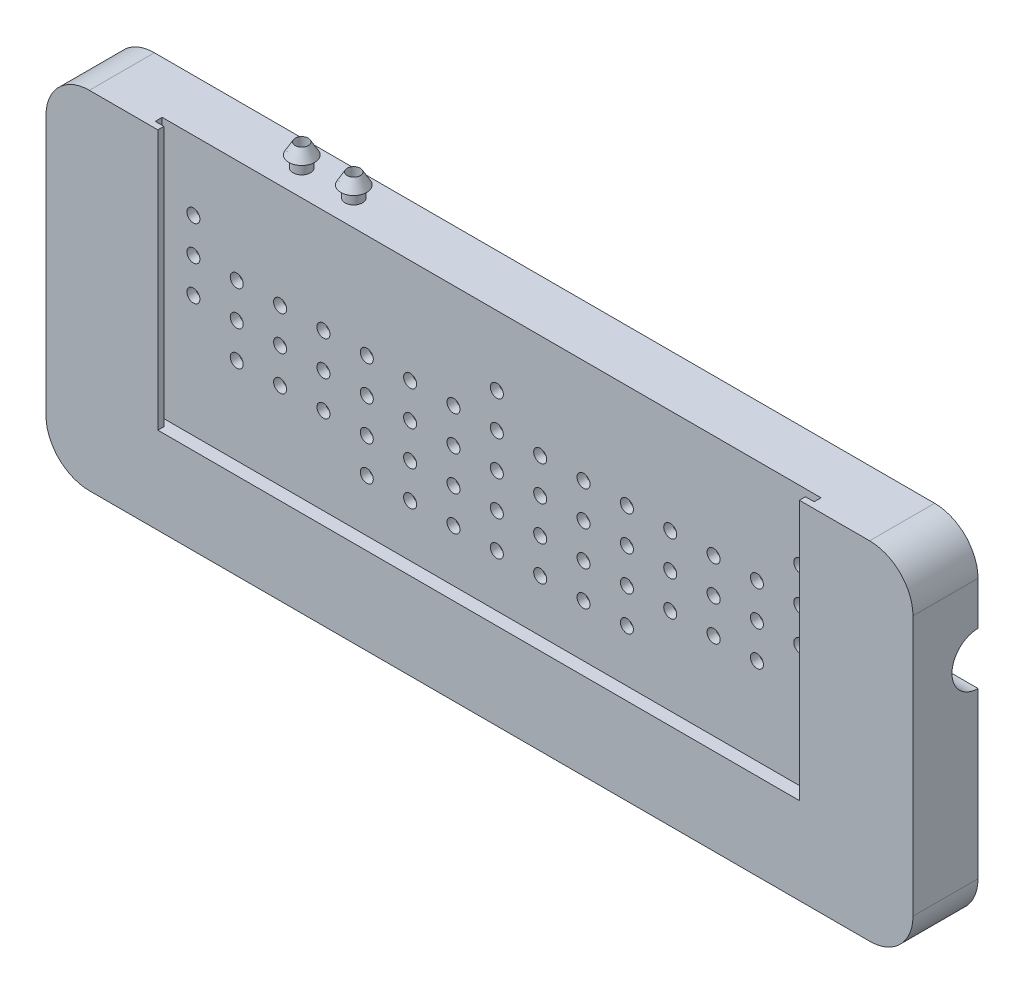
from build123d import *

# Parameters (mm, degrees)
CROQUIS2_W               = 50
CROQUIS2_H               = 40
SALIENTE_EXTRUIR1_DEPTH  = 7.5
CORTAR_EXTRUIR1_DEPTH    = 5
REDONDEO1_R              = 5
CROQUIS5_W               = 12.5
CROQUIS5_H               = 7.5
CORTAR_EXTRUIR2_DEPTH    = 3.5
CROQUIS6_W               = 12.5
CROQUIS6_H               = 3.5
SALIENTE_EXTRUIR5_DEPTH  = 3.5
CORTAR_EXTRUIR3_DEPTH    = 10
CROQUIS4_R               = 4
CORTAR_EXTRUIR4_DEPTH    = 3
CROQUIS9_W               = 102
CROQUIS9_H               = 42
CORTAR_EXTRUIR5_DEPTH    = 13
CROQUIS10_W              = 12.5
CROQUIS10_H              = 4
SALIENTE_EXTRUIR6_DEPTH  = 3.5
CROQUIS12_R              = 0.75
CROQUIS12_R_2            = 0.750000002
CORTAR_EXTRUIR6_DEPTH    = 2.5
CORTAR_EXTRUIR7_DEPTH    = 30
CORTAR_EXTRUIR8_REACH    = 87.33
CROQUIS17_R              = 0.75
CROQUIS18_R              = 1
CROQUIS18_R_2            = 0.75
SALIENTE_EXTRUIR9_DEPTH  = 1.3
CROQUIS20_R              = 1
CROQUIS20_R_2            = 0.75
SALIENTE_EXTRUIR10_DEPTH = 1.3
MATRIZL1_COUNT           = 2
MATRIZL1_PITCH           = 6
CORTAR_EXTRUIR10_REACH   = 88.579
CROQUIS22_R              = 0.75
CROQUIS23_R              = 1
CROQUIS23_R_2            = 0.75
SALIENTE_EXTRUIR11_DEPTH = 1.3
MATRIZL2_COUNT           = 2
MATRIZL2_PITCH           = 6
MATRIZL3_COUNT           = 2
MATRIZL3_PITCH           = 6


with BuildPart() as part:
    # Croquis2 → Saliente-Extruir1 (new body)
    with BuildSketch(Plane.XY):
        Rectangle(CROQUIS2_W, CROQUIS2_H)
    saliente_extruir1 = extrude(amount=SALIENTE_EXTRUIR1_DEPTH)

    # Croquis3 → Cortar-Extruir1 (cut)
    with BuildSketch(Plane.XY.offset(7.5)):
        with BuildLine():
            Line((19.901237938, 10.279897032), (22.822017531, 17.279897032))
            Line((22.822017531, 17.279897032), (24, 15.279897032))
            Line((24, 15.279897032), (25, 15.279897032))
            Line((25, 15.279897032), (25, -14.629122871))
            ThreePointArc((25, -14.629122871), (20.554365751, -11.20741121), (15.817639155, -8.201550981))
            add(Edge.make_bspline(
                [(15.817639155, -8.201550981), (6.428363836, -3.289480245), (3.480591711, -7.371484759)],
                knots=[5.017938201, 5.017938201, 5.017938201, 6.283185307, 6.283185307, 6.283185307], degree=2, weights=[1, 0.806479077, 1]))
            add(Edge.make_bspline(
                [(3.480591711, -7.371484759), (3.499026777, -1.865901054), (-8.816349071, -0.309137944)],
                knots=[3.141592654, 3.141592654, 3.141592654, 4.433520913, 4.433520913, 4.433520913], degree=2, weights=[1, 0.798519762, 1]))
            ThreePointArc((-8.816349071, -0.309137944), (-13.59205679, -0.015988385), (-18.376149655, -0.091990716))
            ThreePointArc((-18.376149655, -0.091990716), (-14.787337114, 10.909903735), (-5.334178799, 17.585160647))
            add(Edge.make_bspline(
                [(-5.334178799, 17.585160647), (-22.119144034, -3.87776365), (19.901237938, 10.279897032)],
                knots=[5.966710887, 5.966710887, 5.966710887, 8.531517406, 8.531517406, 8.531517406], degree=2, weights=[1, 0.284412024, 1]))
        make_face()
    cortar_extruir1 = extrude(amount=-CORTAR_EXTRUIR1_DEPTH, mode=Mode.SUBTRACT)

    # Simetría1: Saliente-Extruir1, Cortar-Extruir1 across plane
    add(saliente_extruir1.mirror(Plane(origin=(25, 20, 7.5), x_dir=(0, 0, 1), z_dir=(-1, 0, 0))))
    add(cortar_extruir1.mirror(Plane(origin=(25, 20, 7.5), x_dir=(0, 0, 1), z_dir=(-1, 0, 0))), mode=Mode.SUBTRACT)

    # Redondeo1
    redondeo1_edges = [part.edges().sort_by_distance(p)[0] for p in [
        (75, -20, 3.75),
        (75, 20, 3.75),
        (-25, -20, 3.75),
        (-25, 20, 3.75),
    ]]
    fillet(redondeo1_edges, radius=REDONDEO1_R)

    # Croquis5 → Cortar-Extruir2 (cut)
    with BuildSketch(Plane(origin=(0, 20, 0), x_dir=(1, 0, 0), z_dir=(0, 1, 0))):
        with Locations((6.25, -3.75)):
            Rectangle(CROQUIS5_W, CROQUIS5_H)
        with Locations((43.75, -3.75)):
            Rectangle(CROQUIS5_W, CROQUIS5_H)
    cortar_extruir2 = extrude(amount=-CORTAR_EXTRUIR2_DEPTH, mode=Mode.SUBTRACT)

    # Croquis6 → Saliente-Extruir5 (add)
    with BuildSketch(Plane(origin=(0, 16.5, 0), x_dir=(1, 0, 0), z_dir=(0, 1, 0))):
        with Locations((6.25, -5.75)):
            Rectangle(CROQUIS6_W, CROQUIS6_H)
        with Locations((43.75, -5.75)):
            Rectangle(CROQUIS6_W, CROQUIS6_H)
    saliente_extruir5 = extrude(amount=SALIENTE_EXTRUIR5_DEPTH)

    # Simetría2: Cortar-Extruir2, Saliente-Extruir5 across plane
    add(cortar_extruir2.mirror(Plane.ZX), mode=Mode.SUBTRACT)
    add(saliente_extruir5.mirror(Plane.ZX))

    # Croquis8 → Cortar-Extruir3 (cut)
    with BuildSketch(Plane(origin=(75, 0, 0), x_dir=(0, 0, -1), z_dir=(1, 0, 0))):
        with BuildLine():
            Line((-7.5, 4), (-7.5, 10))
            ThreePointArc((-7.5, 10), (-4.5, 7), (-7.5, 4))
        make_face()
    extrude(amount=-CORTAR_EXTRUIR3_DEPTH, mode=Mode.SUBTRACT)

    # Croquis4 → Cortar-Extruir4 (cut)
    with BuildSketch(Plane.XY.offset(7.5)):
        with Locations((-19.5, 14.5)):
            Circle(CROQUIS4_R)
        with Locations((69.5, 14.5)):
            Circle(CROQUIS4_R)
        with Locations(Location((-19.5, -14.5, 0), (0, 0, 180))):
            Circle(CROQUIS4_R)
        with Locations(Location((69.5, -14.5, 0), (0, 0, 180))):
            Circle(CROQUIS4_R)
    extrude(amount=-CORTAR_EXTRUIR4_DEPTH, mode=Mode.SUBTRACT)


with BuildPart() as body_2:
    # Simetría4: mirrored copy
    add(part.part.mirror(Plane.XY))

    # Croquis10 → Saliente-Extruir6 (add)
    with BuildSketch(Plane(origin=(0, 16.5, 0), x_dir=(1, 0, 0), z_dir=(0, 1, 0))):
        with Locations((43.75, 2)):
            Rectangle(CROQUIS10_W, CROQUIS10_H)
        with Locations((6.25, 2)):
            Rectangle(CROQUIS10_W, CROQUIS10_H)
    saliente_extruir6 = extrude(amount=SALIENTE_EXTRUIR6_DEPTH)

    # Simetría5: Saliente-Extruir6 across plane
    add(saliente_extruir6.mirror(Plane.ZX))

    # Croquis12 → Cortar-Extruir6 (cut)
    with BuildSketch(Plane(origin=(0, 0, -2.5), x_dir=(-1, 0, 0), z_dir=(0, 0, -1))):
        with Locations((-25.5, 0)):
            Circle(CROQUIS12_R)
        with Locations((-20.5, 0)):
            Circle(CROQUIS12_R)
        with Locations((-15.5, 0)):
            Circle(CROQUIS12_R)
        with Locations((-10.5, 0)):
            Circle(CROQUIS12_R)
        with Locations((-5.5, 0)):
            Circle(CROQUIS12_R)
        with Locations((-0.5, 0)):
            Circle(CROQUIS12_R)
        with Locations((4.5, 0)):
            Circle(CROQUIS12_R)
        with Locations((-30.5, 0)):
            Circle(CROQUIS12_R)
        with Locations((-35.5, 0)):
            Circle(CROQUIS12_R)
        with Locations((-40.5, 0)):
            Circle(CROQUIS12_R)
        with Locations((-45.5, 0)):
            Circle(CROQUIS12_R)
        with Locations((-50.5, 0)):
            Circle(CROQUIS12_R)
        with Locations((-55.5, 0)):
            Circle(CROQUIS12_R)
        with Locations((-25.5, 4)):
            Circle(CROQUIS12_R)
        with Locations((-25.5, 8)):
            Circle(CROQUIS12_R)
        with Locations((-25.5, 12)):
            Circle(CROQUIS12_R)
        with Locations((-25.5, -4)):
            Circle(CROQUIS12_R)
        with Locations((-20.5, 4)):
            Circle(CROQUIS12_R)
        with Locations((-15.5, 4)):
            Circle(CROQUIS12_R)
        with Locations((-10.5, 4)):
            Circle(CROQUIS12_R)
        with Locations((-5.5, 4)):
            Circle(CROQUIS12_R)
        with Locations((-0.5, 4)):
            Circle(CROQUIS12_R)
        with Locations((4.5, 4)):
            Circle(CROQUIS12_R)
        with Locations((9.5, 4)):
            Circle(CROQUIS12_R)
        with Locations((-20.5, 8)):
            Circle(CROQUIS12_R)
        with Locations((-15.5, 8)):
            Circle(CROQUIS12_R)
        with Locations((-10.5, 8)):
            Circle(CROQUIS12_R)
        with Locations((-5.5, 8)):
            Circle(CROQUIS12_R)
        with Locations((-0.5, 8)):
            Circle(CROQUIS12_R)
        with Locations((4.5, 8)):
            Circle(CROQUIS12_R)
        with Locations((9.5, 8)):
            Circle(CROQUIS12_R)
        with Locations((-30.5, 4)):
            Circle(CROQUIS12_R)
        with Locations((-30.5, 8)):
            Circle(CROQUIS12_R)
        with Locations((-35.5, 4)):
            Circle(CROQUIS12_R)
        with Locations((-35.5, 8)):
            Circle(CROQUIS12_R)
        with Locations((-40.5, 4)):
            Circle(CROQUIS12_R)
        with Locations((-40.5, 8)):
            Circle(CROQUIS12_R)
        with Locations((-45.5, 4)):
            Circle(CROQUIS12_R)
        with Locations((-45.5, 8)):
            Circle(CROQUIS12_R)
        with Locations((-50.5, 4)):
            Circle(CROQUIS12_R)
        with Locations((-50.5, 8)):
            Circle(CROQUIS12_R)
        with Locations((-55.5, 4)):
            Circle(CROQUIS12_R)
        with Locations((-55.5, 8)):
            Circle(CROQUIS12_R)
        with Locations((-60.5, 4)):
            Circle(CROQUIS12_R)
        with Locations((-60.5, 8)):
            Circle(CROQUIS12_R)
        with Locations((-30.5, -4.000000654)):
            Circle(CROQUIS12_R_2)
        with Locations((-35.5, -4.000000654)):
            Circle(CROQUIS12_R_2)
        with Locations((-20.5, -4.000000654)):
            Circle(CROQUIS12_R_2)
        with Locations((-15.5, -4.000000654)):
            Circle(CROQUIS12_R_2)
        with Locations((-10.5, -4.000000654)):
            Circle(CROQUIS12_R_2)
        with Locations((-40.5, -4.000000654)):
            Circle(CROQUIS12_R_2)
        with Locations((9.5, 12)):
            Circle(CROQUIS12_R)
        with Locations((-60.5, 12)):
            Circle(CROQUIS12_R)
    extrude(amount=-CORTAR_EXTRUIR6_DEPTH, mode=Mode.SUBTRACT)

    # Croquis13 → Cortar-Extruir7 (cut)
    with BuildSketch(Plane(origin=(0, 20, 0), x_dir=(1, 0, 0), z_dir=(0, 1, 0))):
        Polygon((-13.1, 0.7), (-12.1, 0.7), (-12.1, 0), (61.9, 0), (61.9, 0.7), (62.9, 0.7), (62.9, 1.5), (-13.1, 1.5), align=None)
    extrude(amount=-CORTAR_EXTRUIR7_DEPTH, mode=Mode.SUBTRACT)

    # Croquis17 → Cortar-Extruir8 (cut, up to next)
    with BuildSketch(Plane(origin=(0, 20, 0), x_dir=(1, 0, 0), z_dir=(0, 1, 0)), mode=Mode.PRIVATE) as cortar_extruir8_sk1:
        with Locations(Location((0, 4.5, 0), (0, 0, 270))):
            Circle(CROQUIS17_R)
    cortar_extruir8_tool1 = extrude(cortar_extruir8_sk1.sketch, amount=-CORTAR_EXTRUIR8_REACH, mode=Mode.PRIVATE) & body_2.part
    # Croquis17 → Cortar-Extruir8 (cut, up to next)
    with BuildSketch(Plane(origin=(0, 20, 0), x_dir=(1, 0, 0), z_dir=(0, 1, 0)), mode=Mode.PRIVATE) as cortar_extruir8_sk2:
        with Locations(Location((6, 4.5, 0), (0, 0, 270))):
            Circle(CROQUIS17_R)
    cortar_extruir8_tool2 = extrude(cortar_extruir8_sk2.sketch, amount=-CORTAR_EXTRUIR8_REACH, mode=Mode.PRIVATE) & body_2.part
    add(cortar_extruir8_tool1.solids().sort_by_distance((0, 20, -4.5))[0], mode=Mode.SUBTRACT)
    add(cortar_extruir8_tool2.solids().sort_by_distance((6, 20, -4.5))[0], mode=Mode.SUBTRACT)

    # Croquis18 → Saliente-Extruir9 (add)
    with BuildSketch(Plane(origin=(0, 20, 0), x_dir=(1, 0, 0), z_dir=(0, 1, 0))):
        with Locations(Location((0, 4.5, 0), (0, 0, 90))):
            Circle(CROQUIS18_R)
        with Locations(Location((0, 4.5, 0), (0, 0, 270))):
            Circle(CROQUIS18_R_2, mode=Mode.SUBTRACT)
    extrude(amount=SALIENTE_EXTRUIR9_DEPTH)

    # Croquis20 → Saliente-Extruir10 (add)
    with BuildSketch(Plane(origin=(0, 20, 0), x_dir=(1, 0, 0), z_dir=(0, 1, 0))):
        with Locations(Location((6, 4.5, 0), (0, 0, 90))):
            Circle(CROQUIS20_R)
        with Locations(Location((6, 4.5, 0), (0, 0, 270))):
            Circle(CROQUIS20_R_2, mode=Mode.SUBTRACT)
    extrude(amount=SALIENTE_EXTRUIR10_DEPTH)

    # Croquis21 → Revolución1 (revolve)
    with BuildSketch(Plane.ZY, mode=Mode.PRIVATE) as revoluci_n1_sk:
        Polygon((-5.25, 21.3), (-5.5, 21.3), (-6, 21.3), (-5.25, 22.599038106), (-5.25, 21.321653123), align=None)
    revoluci_n1 = revolve(revoluci_n1_sk.sketch.rotate(Axis((0, 21.3, -4.5), (0, 1, 0)), 180), axis=Axis((0, 21.3, -4.5), (0, 1, 0)))

    # MatrizL1: Revolución1 ×2
    with Locations(*[(i * MATRIZL1_PITCH, 0, 0) for i in range(1, MATRIZL1_COUNT)]):
        add(revoluci_n1)

    # Croquis22 → Cortar-Extruir10 (cut, up to next)
    with BuildSketch(Plane.XZ.offset(20), mode=Mode.PRIVATE) as cortar_extruir10_sk1:
        with Locations(Location((60, -4.5, 0), (0, 0, 270))):
            Circle(CROQUIS22_R)
    cortar_extruir10_tool1 = extrude(cortar_extruir10_sk1.sketch, amount=-CORTAR_EXTRUIR10_REACH, mode=Mode.PRIVATE) & body_2.part
    # Croquis22 → Cortar-Extruir10 (cut, up to next)
    with BuildSketch(Plane.XZ.offset(20), mode=Mode.PRIVATE) as cortar_extruir10_sk2:
        with Locations(Location((54, -4.5, 0), (0, 0, 270))):
            Circle(CROQUIS22_R)
    cortar_extruir10_tool2 = extrude(cortar_extruir10_sk2.sketch, amount=-CORTAR_EXTRUIR10_REACH, mode=Mode.PRIVATE) & body_2.part
    add(cortar_extruir10_tool1.solids().sort_by_distance((60, -20, -4.5))[0], mode=Mode.SUBTRACT)
    add(cortar_extruir10_tool2.solids().sort_by_distance((54, -20, -4.5))[0], mode=Mode.SUBTRACT)

    # Croquis23 → Saliente-Extruir11 (add)
    with BuildSketch(Plane(origin=(0, -20, 0), x_dir=(-1, 0, 0), z_dir=(0, -1, 0))):
        with Locations(Location((-60, 4.5, 0), (0, 0, 270))):
            Circle(CROQUIS23_R)
        with Locations(Location((-60, 4.5, 0), (0, 0, 90))):
            Circle(CROQUIS23_R_2, mode=Mode.SUBTRACT)
    saliente_extruir11 = extrude(amount=SALIENTE_EXTRUIR11_DEPTH)

    # MatrizL2: Saliente-Extruir11 ×2
    with Locations(*[(-i * MATRIZL2_PITCH, 0, 0) for i in range(1, MATRIZL2_COUNT)]):
        add(saliente_extruir11)

    # Croquis27 → Revolución2 (revolve)
    with BuildSketch(Plane(origin=(60, 0, 0), x_dir=(0, 0, -1), z_dir=(1, 0, 0)), mode=Mode.PRIVATE) as revoluci_n2_sk:
        Polygon((3.5, -21.3), (3, -21.3), (3.75, -22.8), (3.75, -21.3), (3.545522879, -21.3), align=None)
    revoluci_n2 = revolve(revoluci_n2_sk.sketch.rotate(Axis((60, -21.3, -4.5), (0, -1, 0)), 180), axis=Axis((60, -21.3, -4.5), (0, -1, 0)))

    # MatrizL3: Revolución2 ×2
    with Locations(*[(-i * MATRIZL3_PITCH, 0, 0) for i in range(1, MATRIZL3_COUNT)]):
        add(revoluci_n2)


with BuildPart() as part_1:
    add(part.part)

    # Croquis9 → Cortar-Extruir5 (cut)
    with BuildSketch(Plane.XY):
        with Locations((25.13065077, 0.044165306)):
            Rectangle(CROQUIS9_W, CROQUIS9_H)
    extrude(amount=CORTAR_EXTRUIR5_DEPTH, mode=Mode.SUBTRACT)


solid = body_2.part
